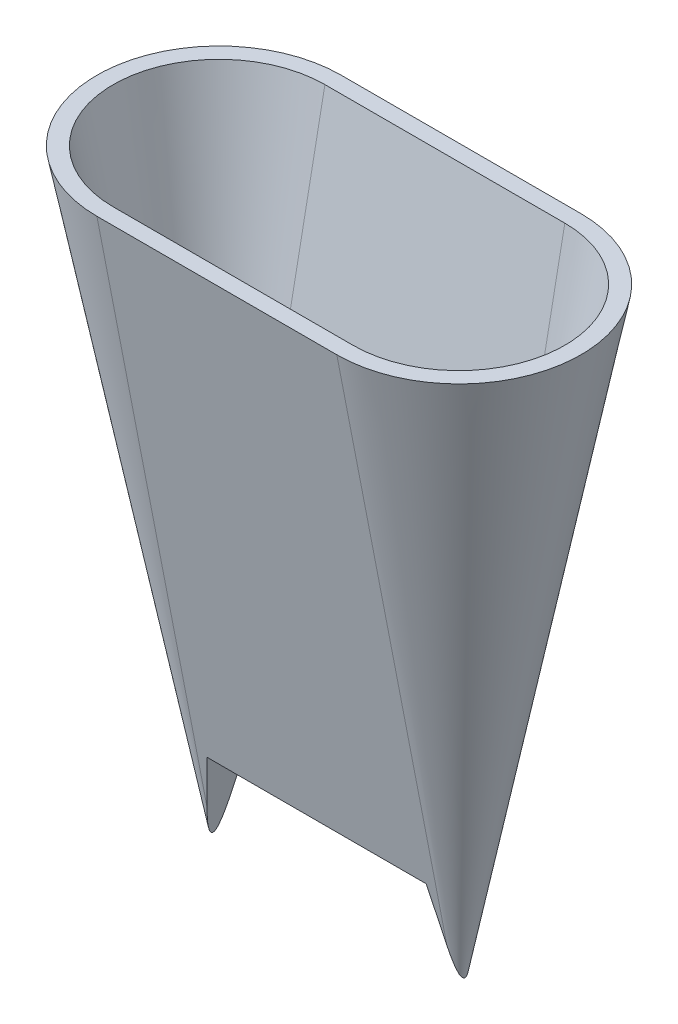
from build123d import *

# Parameters (mm, degrees)
BOSS_EXTRUDE1_DEPTH           = 18
BOSS_EXTRUDE1_TAPER           = 11
BOSS_EXTRUDE1_OTHER_WAY_DEPTH = 40
BOSS_EXTRUDE1_OTHER_WAY_TAPER = -11
SHELL1_T                      = -2
SKETCH2_W                     = 25
SKETCH2_H                     = 3.2
BOSS_EXTRUDE2_DEPTH           = 20
BOSS_EXTRUDE2_TAPER           = 11


with BuildPart() as part:
    # Sketch1 → Boss-Extrude1 (new body)
    with BuildSketch(Plane(origin=(0, 0, 0), x_dir=(1, 0, 0), z_dir=(0, 1, 0))):
        with BuildLine():
            ThreePointArc((-15, 7.5), (-22.5, 0), (-15, -7.5))
            Line((-15, -7.5), (15, -7.5))
            ThreePointArc((15, -7.5), (22.5, 0), (15, 7.5))
            Line((15, 7.5), (-15, 7.5))
        make_face()
    extrude(amount=-BOSS_EXTRUDE1_DEPTH, taper=BOSS_EXTRUDE1_TAPER)

    # Sketch1 → Boss-Extrude1 other way (add)
    with BuildSketch(Plane(origin=(0, 0, 0), x_dir=(1, 0, 0), z_dir=(0, 1, 0))):
        with BuildLine():
            ThreePointArc((-15, 7.5), (-22.5, 0), (-15, -7.5))
            Line((-15, -7.5), (15, -7.5))
            ThreePointArc((15, -7.5), (22.5, 0), (15, 7.5))
            Line((15, 7.5), (-15, 7.5))
        make_face()
    extrude(amount=BOSS_EXTRUDE1_OTHER_WAY_DEPTH, taper=BOSS_EXTRUDE1_OTHER_WAY_TAPER)

    # Shell1
    shell1_openings = [part.faces().sort_by_distance(p)[0] for p in [
        (0, 40, 0),
        (0, -18, 0),
    ]]
    offset(amount=SHELL1_T, openings=shell1_openings, kind=Kind.INTERSECTION)

    # Sketch2 → Boss-Extrude2 (add)
    with BuildSketch(Plane.XZ.offset(18)):
        with BuildLine():
            ThreePointArc((-15, 4.001154436), (-19.001154436, 0), (-15, -4.001154436))
            Line((-15, -4.001154436), (15, -4.001154436))
            ThreePointArc((15, -4.001154436), (19.001154436, 0), (15, 4.001154436))
            Line((15, 4.001154436), (-15, 4.001154436))
        make_face()
        Rectangle(SKETCH2_W, SKETCH2_H, mode=Mode.SUBTRACT)
    extrude(amount=BOSS_EXTRUDE2_DEPTH, taper=BOSS_EXTRUDE2_TAPER)


solid = part.part
